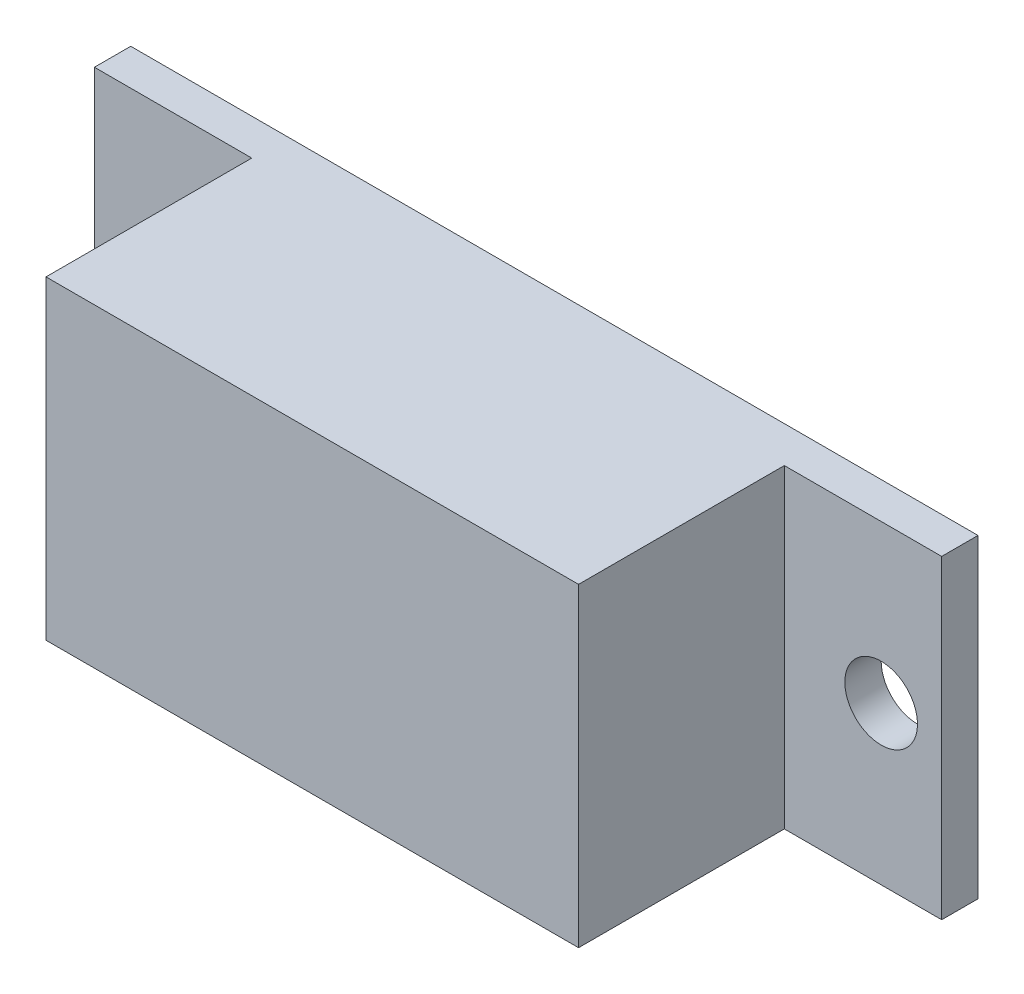
from build123d import *

# Parameters (mm, degrees)
ESBO_O1_W                = 35
ESBO_O1_H                = 13
RESSALTO_EXTRUS_O1_DEPTH = 1.5
ESBO_O2_W                = 22
ESBO_O2_H                = 13
RESSALTO_EXTRUS_O2_DEPTH = 8.5
ESBO_O3_W                = 20
ESBO_O3_H                = 9.770333273
CORTE_EXTRUS_O1_DEPTH    = 2.5
ESBO_O4_R                = 1.5
CORTE_EXTRUS_O2_DEPTH    = 2.5


with BuildPart() as part:
    # Esboço1 → Ressalto-extrusão1 (new body)
    with BuildSketch(Plane.XY):
        with Locations((17.5, 6.5)):
            Rectangle(ESBO_O1_W, ESBO_O1_H)
    extrude(amount=RESSALTO_EXTRUS_O1_DEPTH)

    # Esboço2 → Ressalto-extrusão2 (add)
    with BuildSketch(Plane.XY.offset(1.5)):
        with Locations((17.5, 6.5)):
            Rectangle(ESBO_O2_W, ESBO_O2_H)
    extrude(amount=RESSALTO_EXTRUS_O2_DEPTH)

    # Esboço3 → Corte-extrusão1 (cut)
    with BuildSketch(Plane(origin=(0, 0, 0), x_dir=(-1, 0, 0), z_dir=(0, 0, -1))):
        with Locations((-17.5, 6.364833363)):
            Rectangle(ESBO_O3_W, ESBO_O3_H)
    extrude(amount=-CORTE_EXTRUS_O1_DEPTH, mode=Mode.SUBTRACT)

    # Esboço4 → Corte-extrusão2 (cut)
    with BuildSketch(Plane(origin=(0, 0, 0), x_dir=(-1, 0, 0), z_dir=(0, 0, -1))):
        with Locations((-32.5, 6.5)):
            Circle(ESBO_O4_R)
        with Locations((-2.5, 6.5)):
            Circle(ESBO_O4_R)
    extrude(amount=-CORTE_EXTRUS_O2_DEPTH, mode=Mode.SUBTRACT)


solid = part.part
